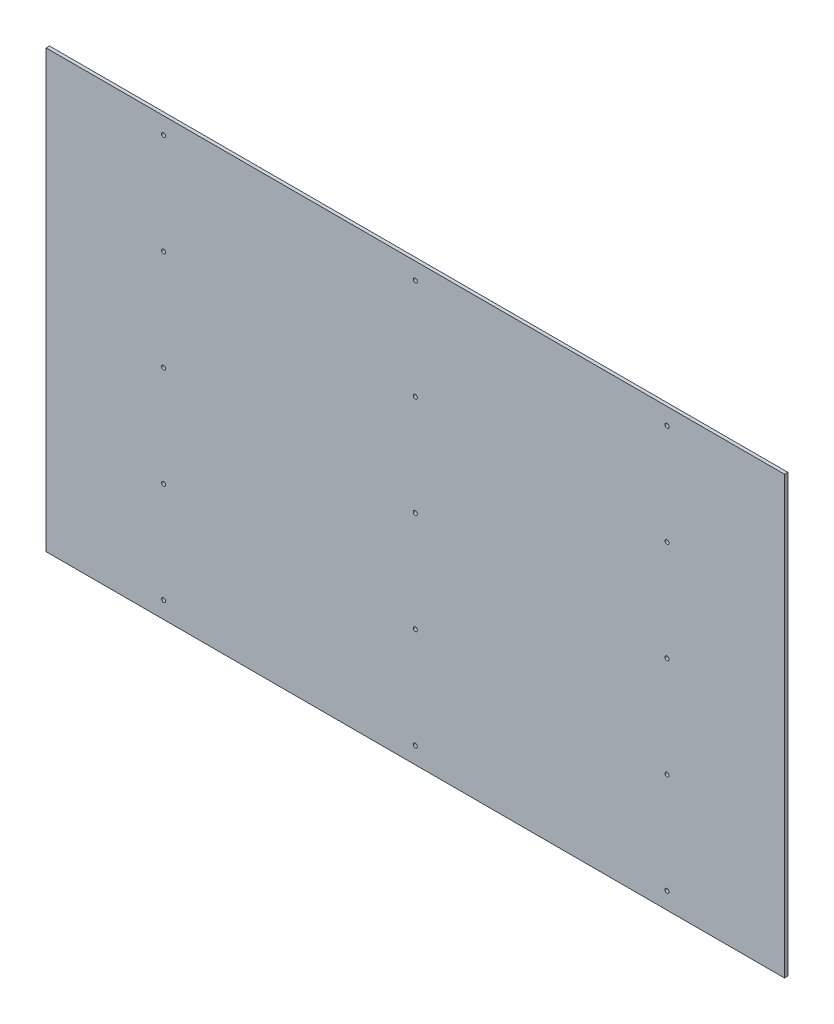
from build123d import *

# Parameters (mm, degrees)
SZKIC1_W                    = 2200
SZKIC1_H                    = 1300
DODANIE_WYCI_GNI_CIE1_DEPTH = 10
OTW_R_POD_RUB_M101_D        = 12
SZYK_LINIOWY1_COUNT         = 5
SZYK_LINIOWY1_PITCH         = 300
SZYK_LINIOWY1_COUNT_DIR2    = 3
SZYK_LINIOWY1_PITCH_DIR2    = 750


with BuildPart() as part:
    # Szkic1 → Dodanie-wyciągnięcie1 (new body)
    with BuildSketch(Plane.XY):
        Rectangle(SZKIC1_W, SZKIC1_H)
    extrude(amount=DODANIE_WYCI_GNI_CIE1_DEPTH)

    # Otwór pod śrubę M101 (through all)
    with Locations(Plane.XY.offset(10)):
        with Locations((-750, -600)):
            otw_r_pod_rub_m101 = Hole(OTW_R_POD_RUB_M101_D / 2)

    # Szyk liniowy1: Otw_r pod _rub_ M101 5 × 3
    with Locations(*[(j * SZYK_LINIOWY1_PITCH_DIR2, i * SZYK_LINIOWY1_PITCH, 0) for i in range(SZYK_LINIOWY1_COUNT) for j in range(SZYK_LINIOWY1_COUNT_DIR2) if (i, j) != (0, 0)]):
        add(otw_r_pod_rub_m101, mode=Mode.SUBTRACT)


solid = part.part
